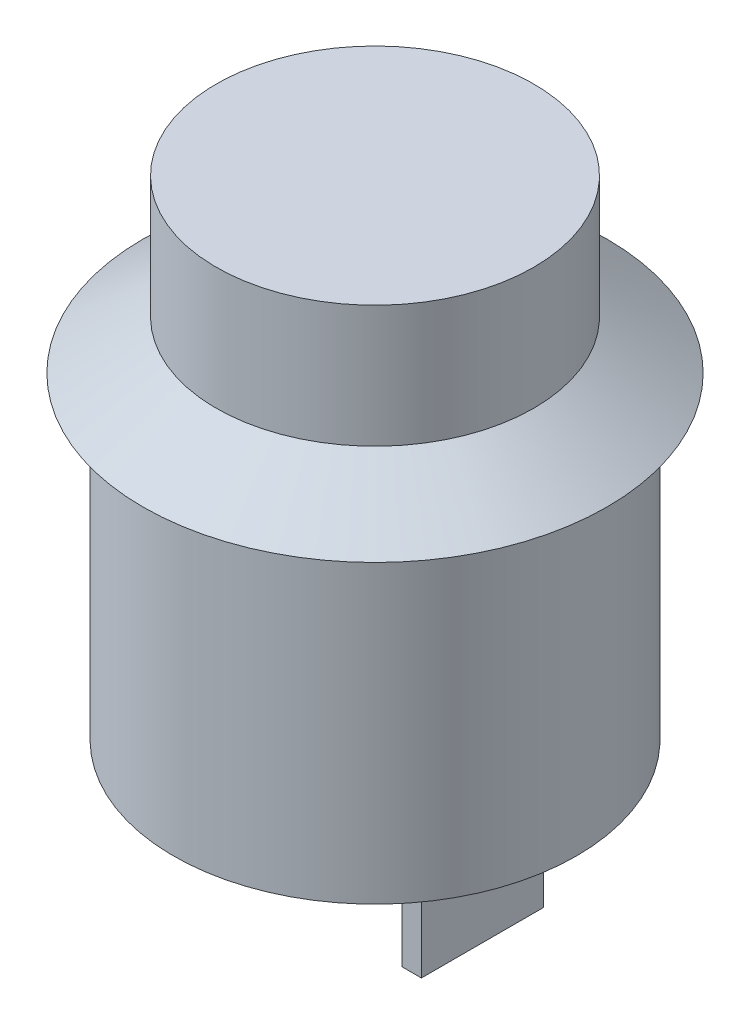
from build123d import *

# Parameters (mm, degrees)
SKETCH_2_W      = 0.8
SKETCH_2_H      = 5
EXTRUDE_1_DEPTH = 5


with BuildPart() as part:
    # Эскиз1 → Повернуть1 (revolve)
    with BuildSketch(Plane.XY):
        Polygon((0, 0), (8.25, 0), (8.25, 13), (9.5, 13), (6.5, 15), (6.5, 20), (0, 20), align=None)
    revolve(axis=Axis((0, -275.009579947, 0), (0, 1, 0)))

    # Эскиз2 → Бобышка-Вытянуть1 (add)
    with BuildSketch(Plane.XZ):
        with Locations((-4, 0)):
            Rectangle(SKETCH_2_W, SKETCH_2_H)
        with Locations((4, 0)):
            Rectangle(SKETCH_2_W, SKETCH_2_H)
    extrude(amount=EXTRUDE_1_DEPTH)


solid = part.part
